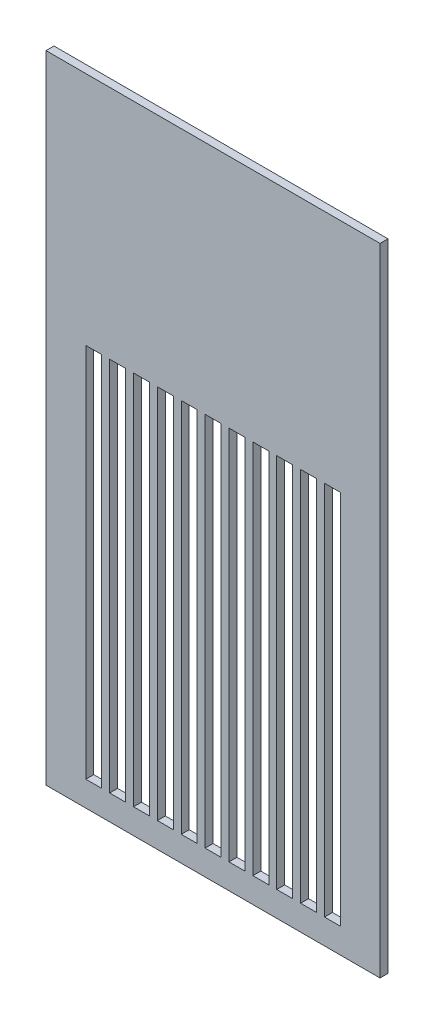
from build123d import *

# Parameters (mm, degrees)
SKETCH1_W           = 133.35
SKETCH1_H           = 254
BOSS_EXTRUDE1_DEPTH = 3.175
SKETCH2_W           = 6.35
SKETCH2_H           = 150
CUT_EXTRUDE1_DEPTH  = 3.175


with BuildPart() as part:
    # Sketch1 → Boss-Extrude1 (new body)
    with BuildSketch(Plane.XY):
        with Locations((66.675, 127)):
            Rectangle(SKETCH1_W, SKETCH1_H)
    extrude(amount=BOSS_EXTRUDE1_DEPTH)

    # Sketch2 → Cut-Extrude1 (cut)
    with BuildSketch(Plane.XY.offset(3.175)):
        with Locations((19.05, 85)):
            Rectangle(SKETCH2_W, SKETCH2_H)
        with Locations((28.58, 85)):
            Rectangle(SKETCH2_W, SKETCH2_H)
        with Locations((38.11, 85)):
            Rectangle(SKETCH2_W, SKETCH2_H)
        with Locations((47.64, 85)):
            Rectangle(SKETCH2_W, SKETCH2_H)
        with Locations((57.17, 85)):
            Rectangle(SKETCH2_W, SKETCH2_H)
        with Locations((66.7, 85)):
            Rectangle(SKETCH2_W, SKETCH2_H)
        with Locations((76.23, 85)):
            Rectangle(SKETCH2_W, SKETCH2_H)
        with Locations((85.76, 85)):
            Rectangle(SKETCH2_W, SKETCH2_H)
        with Locations((95.29, 85)):
            Rectangle(SKETCH2_W, SKETCH2_H)
        with Locations((104.82, 85)):
            Rectangle(SKETCH2_W, SKETCH2_H)
        with Locations((114.35, 85)):
            Rectangle(SKETCH2_W, SKETCH2_H)
    extrude(amount=-CUT_EXTRUDE1_DEPTH, mode=Mode.SUBTRACT)


solid = part.part
